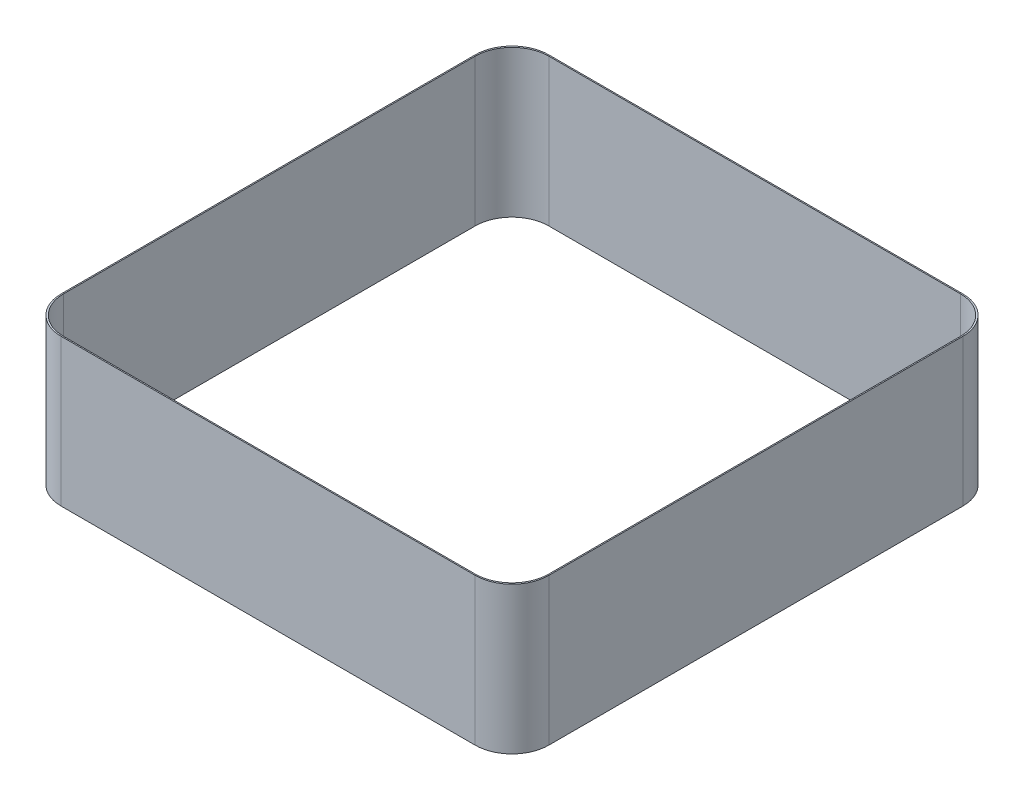
from build123d import *

# Parameters (mm, degrees)
BOSS_EXTRUDE1_DEPTH = 6.35


with BuildPart() as part:
    # Sketch2 → Boss-Extrude1 (new body)
    with BuildSketch(Plane(origin=(0, 0, 0), x_dir=(1, 0, 0), z_dir=(0, 1, 0))):
        with BuildLine():
            Line((-8.9408, -10.5283), (8.9408, -10.5283))
            ThreePointArc((8.9408, -10.5283), (10.063332015, -10.063332015), (10.5283, -8.9408))
            Line((10.5283, -8.9408), (10.5283, 8.9408))
            ThreePointArc((10.5283, 8.9408), (10.063332015, 10.063332015), (8.9408, 10.5283))
            Line((8.9408, 10.5283), (-8.9408, 10.5283))
            ThreePointArc((-8.9408, 10.5283), (-10.063332015, 10.063332015), (-10.5283, 8.9408))
            Line((-10.5283, 8.9408), (-10.5283, -8.9408))
            ThreePointArc((-10.5283, -8.9408), (-10.063332015, -10.063332015), (-8.9408, -10.5283))
        make_face()
        with BuildLine():
            Line((-8.89, -10.4775), (8.89, -10.4775))
            ThreePointArc((8.89, -10.4775), (10.012532015, -10.012532015), (10.4775, -8.89))
            Line((10.4775, -8.89), (10.4775, 8.89))
            ThreePointArc((10.4775, 8.89), (10.012532015, 10.012532015), (8.89, 10.4775))
            Line((8.89, 10.4775), (-8.89, 10.4775))
            ThreePointArc((-8.89, 10.4775), (-10.012532015, 10.012532015), (-10.4775, 8.89))
            Line((-10.4775, 8.89), (-10.4775, -8.89))
            ThreePointArc((-10.4775, -8.89), (-10.012532015, -10.012532015), (-8.89, -10.4775))
        make_face(mode=Mode.SUBTRACT)
    extrude(amount=BOSS_EXTRUDE1_DEPTH)


solid = part.part
